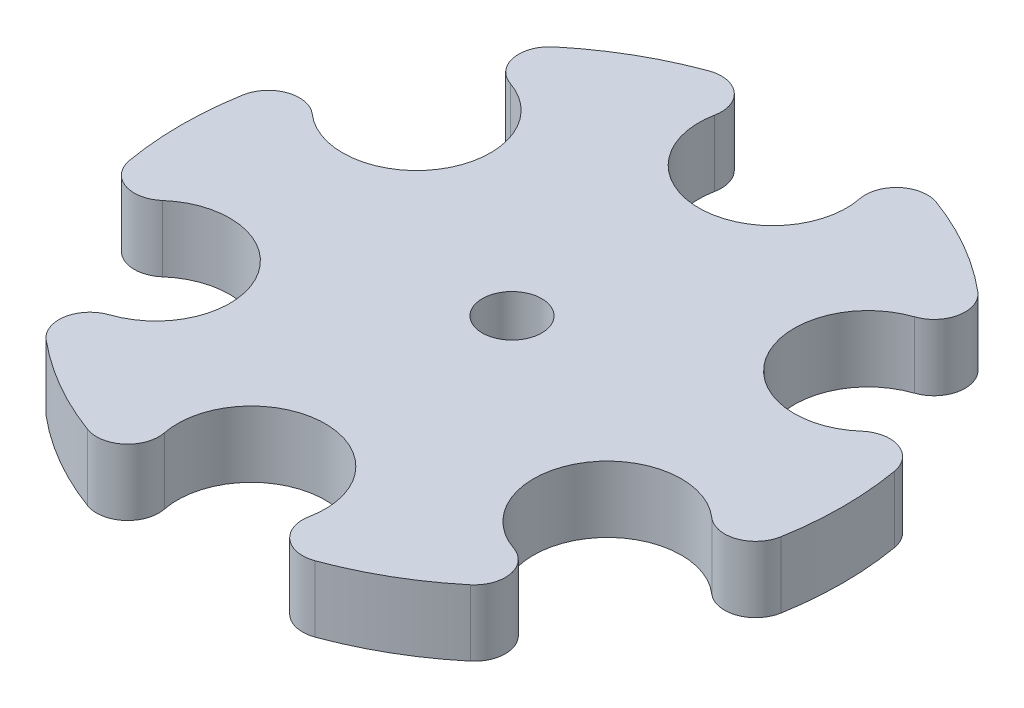
from build123d import *

# Parameters (mm, degrees)
CROQUIS1_R                   = 7.65
SALIENTE_EXTRUIR1_DEPTH      = 8.5
CROQUIS2_R                   = 7.65
CROQUIS2_R_2                 = 5
SALIENTE_EXTRUIR2_DEPTH      = 21.5
SALIENTE_EXTRUIR3_REACH      = 132.896
SALIENTE_EXTRUIR3_END_RADIUS = 7.65
SALIENTE_EXTRUIR3_START      = 12
CROQUIS3_R                   = 6.5
CORTAR_EXTRUIR1_REACH        = 129.309
CORTAR_EXTRUIR1_END_RADIUS   = 5
CROQUIS4_R                   = 2.25


with BuildPart() as part:
    # Croquis1 → Saliente-Extruir1 (new, symmetric)
    with BuildSketch(Plane(origin=(0, 0, 0), x_dir=(1, 0, 0), z_dir=(0, 1, 0))):
        with BuildLine():
            ThreePointArc((-18.62950636, 70.733830846), (-21.266037972, 78.379045573), (-29.224003483, 79.818278736))
            ThreePointArc((-29.224003483, 79.818278736), (-42.5, 73.612159322), (-54.51265533, 65.217868785))
            ThreePointArc((-54.51265533, 65.217868785), (-57.245225604, 57.606451909), (-51.942541239, 51.500541191))
            ThreePointArc((-51.942541239, 51.500541191), (-41.569219382, 24), (-70.572047599, 19.233289655))
            ThreePointArc((-70.572047599, 19.233289655), (-78.511263577, 20.772593665), (-83.736658814, 14.600409951))
            ThreePointArc((-83.736658814, 14.600409951), (-85, 0), (-83.736658814, -14.600409951))
            ThreePointArc((-83.736658814, -14.600409951), (-78.511263577, -20.772593665), (-70.572047599, -19.233289655))
            ThreePointArc((-70.572047599, -19.233289655), (-41.569219382, -24), (-51.942541239, -51.500541191))
            ThreePointArc((-51.942541239, -51.500541191), (-57.245225604, -57.606451909), (-54.51265533, -65.217868785))
            ThreePointArc((-54.51265533, -65.217868785), (-42.5, -73.612159322), (-29.224003483, -79.818278736))
            ThreePointArc((-29.224003483, -79.818278736), (-21.266037972, -78.379045573), (-18.62950636, -70.733830846))
            ThreePointArc((-18.62950636, -70.733830846), (0, -48), (18.62950636, -70.733830846))
            ThreePointArc((18.62950636, -70.733830846), (21.266037972, -78.379045573), (29.224003483, -79.818278736))
            ThreePointArc((29.224003483, -79.818278736), (42.5, -73.612159322), (54.51265533, -65.217868785))
            ThreePointArc((54.51265533, -65.217868785), (57.245225604, -57.606451909), (51.942541239, -51.500541191))
            ThreePointArc((51.942541239, -51.500541191), (41.569219382, -24), (70.572047599, -19.233289655))
            ThreePointArc((70.572047599, -19.233289655), (78.511263577, -20.772593665), (83.736658814, -14.600409951))
            ThreePointArc((83.736658814, -14.600409951), (85, 0), (83.736658814, 14.600409951))
            ThreePointArc((83.736658814, 14.600409951), (78.511263577, 20.772593665), (70.572047599, 19.233289655))
            ThreePointArc((70.572047599, 19.233289655), (41.569219382, 24), (51.942541239, 51.500541191))
            ThreePointArc((51.942541239, 51.500541191), (57.245225604, 57.606451909), (54.51265533, 65.217868785))
            ThreePointArc((54.51265533, 65.217868785), (42.5, 73.612159322), (29.224003483, 79.818278736))
            ThreePointArc((29.224003483, 79.818278736), (21.266037972, 78.379045573), (18.62950636, 70.733830846))
            ThreePointArc((18.62950636, 70.733830846), (0, 48), (-18.62950636, 70.733830846))
        make_face()
        with Locations(Location((0, 0, 0), (0, 0, 270))):
            Circle(CROQUIS1_R, mode=Mode.SUBTRACT)
    extrude(amount=SALIENTE_EXTRUIR1_DEPTH, both=True)


with BuildPart() as body_2:
    # Croquis2 → Saliente-Extruir2 (new body)
    with BuildSketch(Plane(origin=(0, 0, 0), x_dir=(1, 0, 0), z_dir=(0, 1, 0))):
        with Locations(Location((0, 0, 0), (0, 0, 270))):
            Circle(CROQUIS2_R)
        with Locations(Location((0, 0, 0), (0, 0, 270))):
            Circle(CROQUIS2_R_2, mode=Mode.SUBTRACT)
    extrude(amount=SALIENTE_EXTRUIR2_DEPTH)

    # Simetría3: body 2 across plane


with BuildPart() as body_2_1:
    add(body_2.part)
    add(body_2.part.mirror(Plane.ZX))

    # Saliente-Extruir3: up to this cylinder (the profile starts outside it)
    saliente_extruir3_end = Plane(origin=(0, 15, 0), z_dir=(0, -1, 0)) * Cylinder(SALIENTE_EXTRUIR3_END_RADIUS, 282.092, mode=Mode.PRIVATE)
    # Croquis3 → Saliente-Extruir3 (add, up to the surface)
    with BuildSketch(Plane.XY.offset(SALIENTE_EXTRUIR3_START), mode=Mode.PRIVATE) as saliente_extruir3_sk1:
        with Locations((0, 15)):
            Circle(CROQUIS3_R)
        Polygon((0, 10.958548116), (3.5, 12.979274058), (3.5, 17.020725942), (0, 19.041451884), (-3.5, 17.020725942), (-3.5, 12.979274058), align=None, mode=Mode.SUBTRACT)
    saliente_extruir3_tool1 = extrude(saliente_extruir3_sk1.sketch, amount=-SALIENTE_EXTRUIR3_REACH, mode=Mode.PRIVATE) - saliente_extruir3_end
    add(saliente_extruir3_tool1.solids().sort_by_distance((-6.316152, 15, 12))[0])

    # Cortar-Extruir1: up to this cylinder (the profile starts outside it)
    cortar_extruir1_end = Plane(origin=(0, 15, 0), z_dir=(0, -1, 0)) * Cylinder(CORTAR_EXTRUIR1_END_RADIUS, 269.618, mode=Mode.PRIVATE)
    # Croquis4 → Cortar-Extruir1 (cut, up to the surface)
    with BuildSketch(Plane.XY.offset(12), mode=Mode.PRIVATE) as cortar_extruir1_sk1:
        with Locations((0, 15)):
            Circle(CROQUIS4_R)
    cortar_extruir1_tool1 = extrude(cortar_extruir1_sk1.sketch, amount=-CORTAR_EXTRUIR1_REACH, mode=Mode.PRIVATE) - cortar_extruir1_end
    add(cortar_extruir1_tool1.solids().sort_by_distance((0, 15, 12))[0], mode=Mode.SUBTRACT)


solid = part.part
